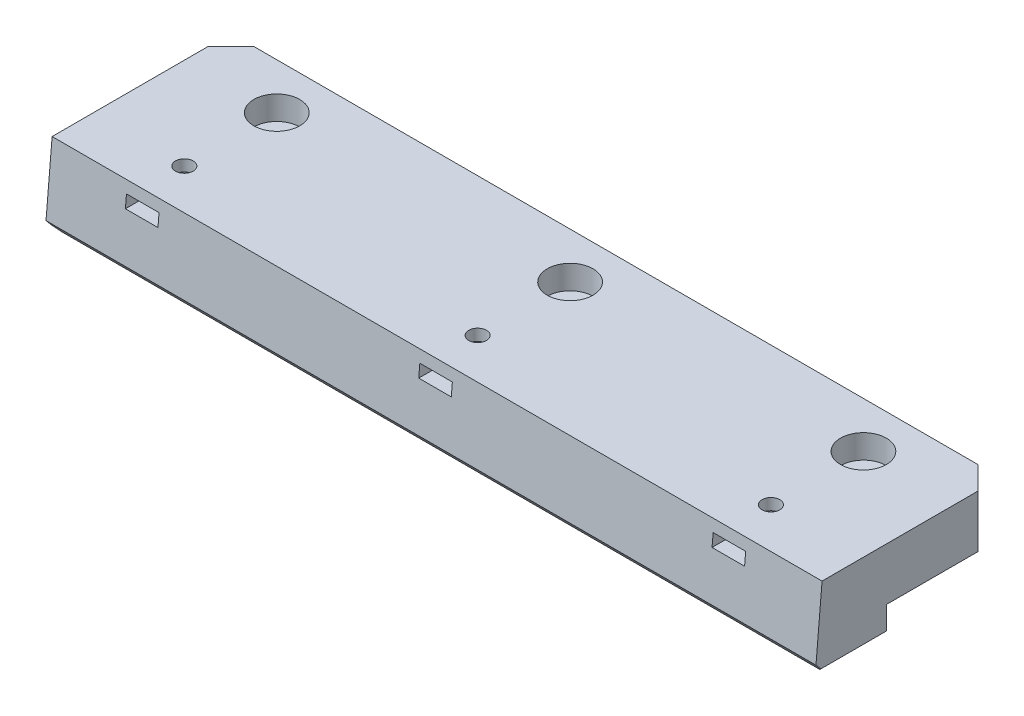
from build123d import *

# Parameters (mm, degrees)
SKETCH1_W             = 25.4
SKETCH1_H             = 9.525
BOSS_EXTRUDE1_DEPTH   = 106.68
BOSS_EXTRUDE2_DEPTH   = 213.36
CHAMFER1_SIZE         = 6.35
CHAMFER2_SIZE         = 3.175
CHAMFER2_SIZE2        = 2.93072295
F_8_CLEARANCE_HOLE1_D = 4.9149
CHAMFER3_SIZE         = 1.5875
BOSS_EXTRUDE3_DEPTH   = 3.429
SKETCH6_W             = 15.367
SKETCH6_H             = 20.192862299
SKETCH6_R             = 2.45745
BOSS_EXTRUDE4_DEPTH   = 3.175
SKETCH7_R             = 6.35
BOSS_EXTRUDE5_DEPTH   = 6.604
CUT_EXTRUDE1_DEPTH    = 218.112793351


with BuildPart() as part:
    # Sketch1 → Boss-Extrude1 (new, symmetric)
    with BuildSketch(Plane(origin=(0, 0, 0), x_dir=(0, 0, -1), z_dir=(1, 0, 0))):
        Rectangle(SKETCH1_W, SKETCH1_H)
    extrude(amount=BOSS_EXTRUDE1_DEPTH, both=True)

    # Sketch2 → Boss-Extrude2 (add, through all)
    with BuildSketch(Plane.ZY.offset(106.68)):
        Polygon((12.7, 4.7625), (37.438033761, 4.7625), (38.828997162, -11.13628443), (12.7, -11.13628443), align=None)
    extrude(amount=-BOSS_EXTRUDE2_DEPTH)

    # Chamfer1
    chamfer1_edges = [part.edges().sort_by_distance(p)[0] for p in [
        (106.68, 0, -12.7),
        (106.68, -7.949392215, 12.7),
        (-106.68, -7.949392215, 12.7),
        (-106.68, 0, -12.7),
    ]]
    chamfer(chamfer1_edges, length=CHAMFER1_SIZE)

    # Chamfer2
    chamfer2_edges = [part.edges().sort_by_distance(p)[0] for p in [
        (0, -11.13628443, 38.828997162),
    ]]
    chamfer2_side = [part.faces().sort_by_distance(p)[0] for p in [
        (0, -3.186892215, 38.133515462),
    ]]
    chamfer(chamfer2_edges, length=CHAMFER2_SIZE, length2=CHAMFER2_SIZE2, reference=chamfer2_side[0])

    # #8 Clearance Hole1 (through all)
    with Locations(Plane(origin=(0, -11.13628443, 0), x_dir=(-1, 0, 0), z_dir=(0, -1, 0))):
        with Locations((-81.28, -25.62613884), (0, 0), (0, -25.62613884), (81.28, -25.62613884), (81.28, 0), (-81.28, 0)):
            Hole(F_8_CLEARANCE_HOLE1_D / 2)

    # Chamfer3
    chamfer3_edges = [part.edges().sort_by_distance(p)[0] for p in [
        (0, -11.13628443, 12.7),
        (-106.68, -11.13628443, 27.474137106),
        (106.68, -11.13628443, 27.474137106),
        (-103.505, -11.13628443, 15.875),
        (103.505, -11.13628443, 15.875),
        (0, -4.7625, -12.7),
        (-103.505, -4.7625, -9.525),
        (103.505, -4.7625, -9.525),
        (-106.68, -4.7625, 6.35),
        (106.68, -4.7625, 6.35),
    ]]
    chamfer(chamfer3_edges, length=CHAMFER3_SIZE)

    # Sketch5 → Boss-Extrude3 (add)
    with BuildSketch(Plane(origin=(0, 4.7625, 0), x_dir=(1, 0, 0), z_dir=(0, 1, 0))):
        Polygon((85.7885, -37.438033761), (85.7885, -23.023155151), (81.28, -20.420171462), (76.7715, -23.023155151), (76.7715, -37.438033761), (73.5965, -37.438033761), (73.5965, -17.245171462), (88.9635, -17.245171462), (88.9635, -37.438033761), align=None)
        Polygon((4.5085, -37.438033761), (4.5085, -23.023155151), (0, -20.420171462), (-4.5085, -23.023155151), (-4.5085, -37.438033761), (-7.6835, -37.438033761), (-7.6835, -17.245171462), (7.6835, -17.245171462), (7.6835, -37.438033761), align=None)
        Polygon((-76.7715, -37.438033761), (-76.7715, -23.023155151), (-81.28, -20.420171462), (-85.7885, -23.023155151), (-85.7885, -37.438033761), (-88.9635, -37.438033761), (-88.9635, -17.245171462), (-73.5965, -17.245171462), (-73.5965, -37.438033761), align=None)
    extrude(amount=BOSS_EXTRUDE3_DEPTH)

    # Sketch6 → Boss-Extrude4 (add)
    with BuildSketch(Plane(origin=(0, 8.1915, 0), x_dir=(1, 0, 0), z_dir=(0, 1, 0))):
        with Locations((-81.28, -27.341602612)):
            Rectangle(SKETCH6_W, SKETCH6_H)
        with Locations(Location((-81.28, -25.62613884, 0), (0, 0, 90))):
            Circle(SKETCH6_R, mode=Mode.SUBTRACT)
        with Locations((0, -27.341602612)):
            Rectangle(SKETCH6_W, SKETCH6_H)
        with Locations(Location((0, -25.62613884, 0), (0, 0, 90))):
            Circle(SKETCH6_R, mode=Mode.SUBTRACT)
        with Locations((81.28, -27.341602612)):
            Rectangle(SKETCH6_W, SKETCH6_H)
        with Locations(Location((81.28, -25.62613884, 0), (0, 0, 90))):
            Circle(SKETCH6_R, mode=Mode.SUBTRACT)
    extrude(amount=BOSS_EXTRUDE4_DEPTH)

    # Sketch7 → Boss-Extrude5 (add)
    with BuildSketch(Plane(origin=(0, 4.7625, 0), x_dir=(1, 0, 0), z_dir=(0, 1, 0))):
        Polygon((-73.5965, -17.245171462), (-73.5965, -37.438033761), (-7.6835, -37.438033761), (-7.6835, -17.245171462), (7.6835, -17.245171462), (7.6835, -37.438033761), (73.5965, -37.438033761), (73.5965, -17.245171462), (88.9635, -17.245171462), (88.9635, -37.438033761), (106.68, -37.438033761), (106.68, 6.35), (100.33, 12.7), (-100.33, 12.7), (-106.68, 6.35), (-106.68, -37.438033761), (-88.9635, -37.438033761), (-88.9635, -17.245171462), align=None)
        with Locations(Location((81.28, 0, 0), (0, 0, 90))):
            Circle(SKETCH7_R, mode=Mode.SUBTRACT)
        with Locations(Location((0, 0, 0), (0, 0, 90))):
            Circle(SKETCH7_R, mode=Mode.SUBTRACT)
        with Locations(Location((-81.28, 0, 0), (0, 0, 90))):
            Circle(SKETCH7_R, mode=Mode.SUBTRACT)
    extrude(amount=BOSS_EXTRUDE5_DEPTH)

    # Sketch8 → Cut-Extrude1 (cut, through all)
    with BuildSketch(Plane.ZY.offset(106.68)):
        Polygon((37.438033761, 4.7625), (36.860258627, 11.3665), (37.438033761, 11.3665), align=None)
    extrude(amount=-CUT_EXTRUDE1_DEPTH, mode=Mode.SUBTRACT)


solid = part.part
